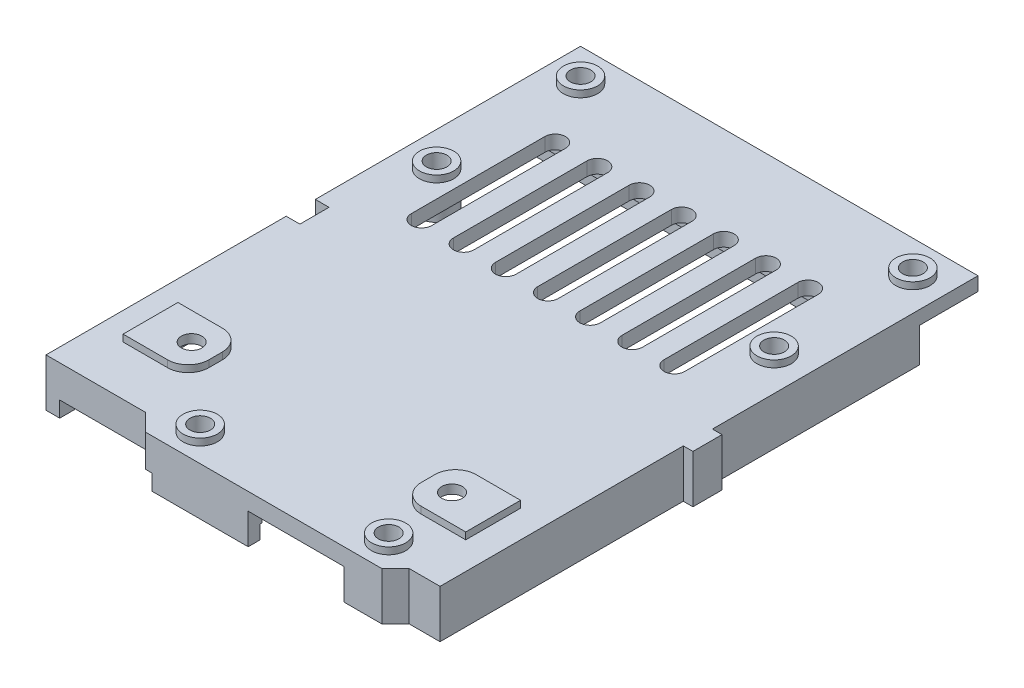
from build123d import *

# Parameters (mm, degrees)
SKETCH1_W            = 58
SKETCH1_H            = 81
SKETCH1_R            = 1.5
BOSS_EXTRUDE1_DEPTH  = 2
SKETCH2_W            = 14
SKETCH2_H            = 2
SKETCH2_W_2          = 2
SKETCH2_H_2          = 65.5
SKETCH2_H_3          = 66
SKETCH2_W_3          = 2.5
SKETCH2_W_4          = 15
BOSS_EXTRUDE2_DEPTH  = 0.5
SKETCH5_W            = 14
SKETCH5_H            = 2
BOSS_EXTRUDE3_DEPTH  = 4.5
BOSS_EXTRUDE4_DEPTH  = 2.7
SKETCH7_R            = 1.5
CUT_EXTRUDE1_DEPTH   = 1.7
SKETCH8_R            = 1.5
BOSS_EXTRUDE5_DEPTH  = 1
SKETCH9_R            = 2.5
SKETCH9_R_2          = 1.5
BOSS_EXTRUDE6_DEPTH  = 1
BOSS_EXTRUDE7_START  = 3
BOSS_EXTRUDE7_DEPTH  = 3
SKETCH11_W           = 2
SKETCH11_H           = 4.25
CUT_EXTRUDE2_DEPTH   = 51.450470761
SKETCH12_W           = 1.7
SKETCH12_H           = 6
BOSS_EXTRUDE8_DEPTH  = 3
SKETCH13_W           = 1.4
SKETCH13_H           = 4.25
BOSS_EXTRUDE9_DEPTH  = 7
SKETCH14_W           = 2.5
SKETCH14_H           = 2.5
BOSS_EXTRUDE10_DEPTH = 2.7
CUT_EXTRUDE3_DEPTH   = 51.886245686
SKETCH17_W           = 27.5
SKETCH17_H           = 0.29
SKETCH17_W_2         = 5.5
SKETCH17_W_3         = 37.5
SKETCH17_W_4         = 16.5
SKETCH17_W_5         = 0.5
CUT_EXTRUDE4_DEPTH   = 2


with BuildPart() as part:
    # Sketch1 → Boss-Extrude1 (new body)
    with BuildSketch(Plane(origin=(0, 0, 0), x_dir=(1, 0, 0), z_dir=(0, 1, 0))):
        Rectangle(SKETCH1_W, SKETCH1_H)
        with Locations(Location((24.25, 35.75, 0), (0, 0, 270))):
            Circle(SKETCH1_R, mode=Mode.SUBTRACT)
        with Locations(Location((-24.25, 35.75, 0), (0, 0, 90))):
            Circle(SKETCH1_R, mode=Mode.SUBTRACT)
        with Locations(Location((24, 15.75, 0), (0, 0, 270))):
            Circle(SKETCH1_R, mode=Mode.SUBTRACT)
        with Locations(Location((-24, 14.5, 0), (0, 0, 90))):
            Circle(SKETCH1_R, mode=Mode.SUBTRACT)
        with Locations(Location((19, -26.25, 0), (0, 0, 270))):
            Circle(SKETCH1_R, mode=Mode.SUBTRACT)
        with Locations(Location((19.5, -36, 0), (0, 0, 270))):
            Circle(SKETCH1_R, mode=Mode.SUBTRACT)
        with Locations(Location((-8, -36, 0), (0, 0, 270))):
            Circle(SKETCH1_R, mode=Mode.SUBTRACT)
        with Locations(Location((-19, -26.25, 0), (0, 0, 90))):
            Circle(SKETCH1_R, mode=Mode.SUBTRACT)
        with BuildLine():
            Line((19.7, 26.5), (19.7, 7))
            ThreePointArc((19.7, 7), (18.2, 5.5), (16.7, 7))
            Line((16.7, 7), (16.7, 26.5))
            ThreePointArc((16.7, 26.5), (18.2, 28), (19.7, 26.5))
        make_face(mode=Mode.SUBTRACT)
        with BuildLine():
            Line((13.55, 26.5), (13.55, 7))
            ThreePointArc((13.55, 7), (12.05, 5.5), (10.55, 7))
            Line((10.55, 7), (10.55, 26.5))
            ThreePointArc((10.55, 26.5), (12.05, 28), (13.55, 26.5))
        make_face(mode=Mode.SUBTRACT)
        with BuildLine():
            Line((7.4, 26.5), (7.4, 7))
            ThreePointArc((7.4, 7), (5.9, 5.5), (4.4, 7))
            Line((4.4, 7), (4.4, 26.5))
            ThreePointArc((4.4, 26.5), (5.9, 28), (7.4, 26.5))
        make_face(mode=Mode.SUBTRACT)
        with BuildLine():
            Line((1.25, 26.5), (1.25, 7))
            ThreePointArc((1.25, 7), (-0.25, 5.5), (-1.75, 7))
            Line((-1.75, 7), (-1.75, 26.5))
            ThreePointArc((-1.75, 26.5), (-0.25, 28), (1.25, 26.5))
        make_face(mode=Mode.SUBTRACT)
        with BuildLine():
            Line((-4.9, 26.5), (-4.9, 7))
            ThreePointArc((-4.9, 7), (-6.4, 5.5), (-7.9, 7))
            Line((-7.9, 7), (-7.9, 26.5))
            ThreePointArc((-7.9, 26.5), (-6.4, 28), (-4.9, 26.5))
        make_face(mode=Mode.SUBTRACT)
        with BuildLine():
            Line((-11.05, 26.5), (-11.05, 7))
            ThreePointArc((-11.05, 7), (-12.55, 5.5), (-14.05, 7))
            Line((-14.05, 7), (-14.05, 26.5))
            ThreePointArc((-14.05, 26.5), (-12.55, 28), (-11.05, 26.5))
        make_face(mode=Mode.SUBTRACT)
        with BuildLine():
            Line((-17.2, 26.5), (-17.2, 7))
            ThreePointArc((-17.2, 7), (-18.7, 5.5), (-20.2, 7))
            Line((-20.2, 7), (-20.2, 26.5))
            ThreePointArc((-20.2, 26.5), (-18.7, 28), (-17.2, 26.5))
        make_face(mode=Mode.SUBTRACT)
    extrude(amount=BOSS_EXTRUDE1_DEPTH)

    # Sketch2 → Boss-Extrude2 (add)
    with BuildSketch(Plane.XZ):
        with Locations((10, 39)):
            Rectangle(SKETCH2_W, SKETCH2_H)
        with Locations((-28, 2.75)):
            Rectangle(SKETCH2_W_2, SKETCH2_H_2)
        Polygon((29, -30), (27, -30), (-27, -30), (-27, -32), (29, -32), align=None)
        with Locations((-28, -31)):
            Rectangle(SKETCH2_W_2, SKETCH2_H)
        with Locations((28, 3)):
            Rectangle(SKETCH2_W_2, SKETCH2_H_3)
        with Locations((25.75, 37)):
            Rectangle(SKETCH2_W_3, SKETCH2_H)
        with Locations((28, 37)):
            Rectangle(SKETCH2_W_2, SKETCH2_H)
        Polygon((22.5, 40), (24.5, 38), (24.5, 36), (22.5, 38), (17, 38), (17, 40), align=None)
        with Locations((-4.5, 39)):
            Rectangle(SKETCH2_W_4, SKETCH2_H)
        Polygon((-14.5, 37.5), (-12, 37.5), (-12, 38), (-12, 40), align=None)
        Polygon((-27, 37.5), (-27, 35.5), (-12, 35.5), (-12, 37.5), (-14.5, 37.5), align=None)
        with Locations((-28, 36.5)):
            Rectangle(SKETCH2_W_2, SKETCH2_H)
    extrude(amount=BOSS_EXTRUDE2_DEPTH)

    # Sketch5 → Boss-Extrude3 (add)
    with BuildSketch(Plane.XZ.offset(0.5)):
        Polygon((27, -30), (-27, -30), (-27, 37.5), (-29, 37.5), (-29, -32), (29, -32), (29, 38), (24.5, 38), (22.5, 40), (17, 40), (17, 38), (22.5, 38), (24.5, 36), (27, 36), align=None)
        with Locations((-4, 39)):
            Rectangle(SKETCH5_W, SKETCH5_H)
    extrude(amount=BOSS_EXTRUDE3_DEPTH)

    # Sketch6 → Boss-Extrude4 (add)
    with BuildSketch(Plane.XZ):
        Polygon((-11, 38), (-11, 40), (-12, 40), (-14.5, 37.5), (-27, 37.5), (-27, 35.5), (-12, 35.5), (-12, 38), align=None)
    extrude(amount=BOSS_EXTRUDE4_DEPTH)

    # Sketch7 → Cut-Extrude1 (cut)
    # profile 1 of 2: a face of its own
    with BuildSketch(Plane.XZ):
        with BuildLine():
            Line((-18.5, 30.25), (-25, 30.25))
            Line((-25, 30.25), (-25, 22.25))
            Line((-25, 22.25), (-18.5, 22.25))
            ThreePointArc((-18.5, 22.25), (-16.378679656, 23.128679656), (-15.5, 25.25))
            Line((-15.5, 25.25), (-15.5, 27.25))
            ThreePointArc((-15.5, 27.25), (-16.378679656, 29.371320344), (-18.5, 30.25))
        make_face()
        with Locations(Location((-19, 26.25, 0), (0, 0, 270))):
            Circle(SKETCH7_R, mode=Mode.SUBTRACT)
    # profile 2 of 2: a face of its own
    with BuildSketch(Plane.XZ):
        with BuildLine():
            ThreePointArc((18.5, 30.25), (16.378679656, 29.371320344), (15.5, 27.25))
            Line((15.5, 27.25), (15.5, 25.25))
            ThreePointArc((15.5, 25.25), (16.378679656, 23.128679656), (18.5, 22.25))
            Line((18.5, 22.25), (25, 22.25))
            Line((25, 22.25), (25, 30.25))
            Line((25, 30.25), (18.5, 30.25))
        make_face()
        with Locations(Location((19, 26.25, 0), (0, 0, 270))):
            Circle(SKETCH7_R, mode=Mode.SUBTRACT)
    extrude(amount=-CUT_EXTRUDE1_DEPTH, mode=Mode.SUBTRACT)

    # Sketch8 → Boss-Extrude5 (add)
    # profile 1 of 2: a face of its own
    with BuildSketch(Plane(origin=(0, 2, 0), x_dir=(1, 0, 0), z_dir=(0, 1, 0))):
        with BuildLine():
            Line((25, -22.25), (18.5, -22.25))
            ThreePointArc((18.5, -22.25), (16.378679656, -23.128679656), (15.5, -25.25))
            Line((15.5, -25.25), (15.5, -27.25))
            ThreePointArc((15.5, -27.25), (16.378679656, -29.371320344), (18.5, -30.25))
            Line((18.5, -30.25), (25, -30.25))
            Line((25, -30.25), (25, -22.25))
        make_face()
        with Locations(Location((19, -26.25, 0), (0, 0, 90))):
            Circle(SKETCH8_R, mode=Mode.SUBTRACT)
    # profile 2 of 2: a face of its own
    with BuildSketch(Plane(origin=(0, 2, 0), x_dir=(1, 0, 0), z_dir=(0, 1, 0))):
        with BuildLine():
            Line((-18.5, -22.25), (-25, -22.25))
            Line((-25, -22.25), (-25, -30.25))
            Line((-25, -30.25), (-18.5, -30.25))
            ThreePointArc((-18.5, -30.25), (-16.378679656, -29.371320344), (-15.5, -27.25))
            Line((-15.5, -27.25), (-15.5, -25.25))
            ThreePointArc((-15.5, -25.25), (-16.378679656, -23.128679656), (-18.5, -22.25))
        make_face()
        with Locations(Location((-19, -26.25, 0), (0, 0, 90))):
            Circle(SKETCH8_R, mode=Mode.SUBTRACT)
    extrude(amount=BOSS_EXTRUDE5_DEPTH)

    # Sketch9 → Boss-Extrude6 (add)
    # profile 1 of 6: a face of its own
    with BuildSketch(Plane(origin=(0, 2, 0), x_dir=(1, 0, 0), z_dir=(0, 1, 0))):
        with Locations(Location((-24.25, 35.75, 0), (0, 0, 270))):
            Circle(SKETCH9_R)
        with Locations(Location((-24.25, 35.75, 0), (0, 0, 90))):
            Circle(SKETCH9_R_2, mode=Mode.SUBTRACT)
    # profile 2 of 6: a face of its own
    with BuildSketch(Plane(origin=(0, 2, 0), x_dir=(1, 0, 0), z_dir=(0, 1, 0))):
        with Locations(Location((-24, 14.5, 0), (0, 0, 270))):
            Circle(SKETCH9_R)
        with Locations(Location((-24, 14.5, 0), (0, 0, 90))):
            Circle(SKETCH9_R_2, mode=Mode.SUBTRACT)
    # profile 3 of 6: a face of its own
    with BuildSketch(Plane(origin=(0, 2, 0), x_dir=(1, 0, 0), z_dir=(0, 1, 0))):
        with Locations(Location((-8, -36, 0), (0, 0, 270))):
            Circle(SKETCH9_R)
        with Locations(Location((-8, -36, 0), (0, 0, 270))):
            Circle(SKETCH9_R_2, mode=Mode.SUBTRACT)
    # profile 4 of 6: a face of its own
    with BuildSketch(Plane(origin=(0, 2, 0), x_dir=(1, 0, 0), z_dir=(0, 1, 0))):
        with Locations(Location((19.5, -36, 0), (0, 0, 270))):
            Circle(SKETCH9_R)
        with Locations(Location((19.5, -36, 0), (0, 0, 270))):
            Circle(SKETCH9_R_2, mode=Mode.SUBTRACT)
    # profile 5 of 6: a face of its own
    with BuildSketch(Plane(origin=(0, 2, 0), x_dir=(1, 0, 0), z_dir=(0, 1, 0))):
        with Locations(Location((24, 15.75, 0), (0, 0, 90))):
            Circle(SKETCH9_R)
        with Locations(Location((24, 15.75, 0), (0, 0, 90))):
            Circle(SKETCH9_R_2, mode=Mode.SUBTRACT)
    # profile 6 of 6: a face of its own
    with BuildSketch(Plane(origin=(0, 2, 0), x_dir=(1, 0, 0), z_dir=(0, 1, 0))):
        with Locations(Location((24.25, 35.75, 0), (0, 0, 90))):
            Circle(SKETCH9_R)
        with Locations(Location((24.25, 35.75, 0), (0, 0, 90))):
            Circle(SKETCH9_R_2, mode=Mode.SUBTRACT)
    extrude(amount=BOSS_EXTRUDE6_DEPTH)

    # Sketch10 → Boss-Extrude7 (add)
    with BuildSketch(Plane.XZ.offset(BOSS_EXTRUDE7_START)):
        with BuildLine():
            Line((-5.5, 36), (-6.5, 36))
            ThreePointArc((-6.5, 36), (-8, 34.5), (-9.5, 36))
            Line((-9.5, 36), (-10.5, 36))
            ThreePointArc((-10.5, 36), (-8, 33.5), (-5.5, 36))
        make_face()
        with BuildLine():
            ThreePointArc((-9.5, 36), (-8, 37.5), (-6.5, 36))
            Line((-6.5, 36), (-5.5, 36))
            ThreePointArc((-5.5, 36), (-5.763932023, 37.118033989), (-6.5, 38))
            Line((-6.5, 38), (-9.5, 38))
            ThreePointArc((-9.5, 38), (-10.236067977, 37.118033989), (-10.5, 36))
            Line((-10.5, 36), (-9.5, 36))
        make_face()
        with BuildLine():
            ThreePointArc((-6.5, 38), (-5.763932023, 37.118033989), (-5.5, 36))
            Line((-5.5, 36), (-5.5, 38))
            Line((-5.5, 38), (-6.5, 38))
        make_face()
        with BuildLine():
            Line((-10.5, 38), (-10.5, 36))
            ThreePointArc((-10.5, 36), (-10.236067977, 37.118033989), (-9.5, 38))
            Line((-9.5, 38), (-10.5, 38))
        make_face()
        with BuildLine():
            ThreePointArc((21, 38), (21.736067977, 37.118033989), (22, 36))
            Line((22, 36), (22, 38))
            Line((22, 38), (21, 38))
        make_face()
        with BuildLine():
            ThreePointArc((18, 36), (19.5, 37.5), (21, 36))
            Line((21, 36), (22, 36))
            ThreePointArc((22, 36), (21.736067977, 37.118033989), (21, 38))
            Line((21, 38), (18, 38))
            ThreePointArc((18, 38), (17.263932023, 37.118033989), (17, 36))
            Line((17, 36), (18, 36))
        make_face()
        with BuildLine():
            Line((22, 36), (21, 36))
            ThreePointArc((21, 36), (19.5, 34.5), (18, 36))
            Line((18, 36), (17, 36))
            ThreePointArc((17, 36), (19.5, 33.5), (22, 36))
        make_face()
        with BuildLine():
            Line((17, 38), (17, 36))
            ThreePointArc((17, 36), (17.263932023, 37.118033989), (18, 38))
            Line((18, 38), (17, 38))
        make_face()
        with BuildLine():
            Line((27, -18.25), (27, -13.25))
            Line((27, -13.25), (24, -13.25))
            ThreePointArc((24, -13.25), (25.767766953, -13.982233047), (26.5, -15.75))
            ThreePointArc((26.5, -15.75), (25.767766953, -17.517766953), (24, -18.25))
            Line((24, -18.25), (27, -18.25))
        make_face()
        with BuildLine():
            ThreePointArc((26.5, -15.75), (25.767766953, -13.982233047), (24, -13.25))
            Line((24, -13.25), (24, -14.25))
            ThreePointArc((24, -14.25), (25.060660172, -14.689339828), (25.5, -15.75))
            ThreePointArc((25.5, -15.75), (25.060660172, -16.810660172), (24, -17.25))
            Line((24, -17.25), (24, -18.25))
            ThreePointArc((24, -18.25), (25.767766953, -17.517766953), (26.5, -15.75))
        make_face()
        with BuildLine():
            Line((24, -14.25), (24, -13.25))
            ThreePointArc((24, -13.25), (21.5, -15.75), (24, -18.25))
            Line((24, -18.25), (24, -17.25))
            ThreePointArc((24, -17.25), (22.5, -15.75), (24, -14.25))
        make_face()
        with BuildLine():
            ThreePointArc((26.5, -15.75), (25.767766953, -13.982233047), (24, -13.25))
            Line((24, -13.25), (24, -14.25))
            ThreePointArc((24, -14.25), (25.060660172, -14.689339828), (25.5, -15.75))
            ThreePointArc((25.5, -15.75), (25.060660172, -16.810660172), (24, -17.25))
            Line((24, -17.25), (24, -18.25))
            ThreePointArc((24, -18.25), (25.767766953, -17.517766953), (26.5, -15.75))
        make_face()
        with BuildLine():
            Line((24, -14.25), (24, -13.25))
            ThreePointArc((24, -13.25), (21.5, -15.75), (24, -18.25))
            Line((24, -18.25), (24, -17.25))
            ThreePointArc((24, -17.25), (22.5, -15.75), (24, -14.25))
        make_face()
        with BuildLine():
            ThreePointArc((-24, -17), (-26.5, -14.5), (-24, -12))
            Line((-24, -12), (-27, -12))
            Line((-27, -12), (-27, -17))
            Line((-27, -17), (-24, -17))
        make_face()
        with BuildLine():
            ThreePointArc((-21.5, -14.5), (-22.232233047, -12.732233047), (-24, -12))
            Line((-24, -12), (-24, -13))
            ThreePointArc((-24, -13), (-22.939339828, -13.439339828), (-22.5, -14.5))
            ThreePointArc((-22.5, -14.5), (-22.939339828, -15.560660172), (-24, -16))
            Line((-24, -16), (-24, -17))
            ThreePointArc((-24, -17), (-22.232233047, -16.267766953), (-21.5, -14.5))
        make_face()
        with BuildLine():
            Line((-24, -13), (-24, -12))
            ThreePointArc((-24, -12), (-26.5, -14.5), (-24, -17))
            Line((-24, -17), (-24, -16))
            ThreePointArc((-24, -16), (-25.5, -14.5), (-24, -13))
        make_face()
        with BuildLine():
            ThreePointArc((-21.5, -14.5), (-22.232233047, -12.732233047), (-24, -12))
            Line((-24, -12), (-24, -13))
            ThreePointArc((-24, -13), (-22.939339828, -13.439339828), (-22.5, -14.5))
            ThreePointArc((-22.5, -14.5), (-22.939339828, -15.560660172), (-24, -16))
            Line((-24, -16), (-24, -17))
            ThreePointArc((-24, -17), (-22.232233047, -16.267766953), (-21.5, -14.5))
        make_face()
        with BuildLine():
            Line((-24, -13), (-24, -12))
            ThreePointArc((-24, -12), (-26.5, -14.5), (-24, -17))
            Line((-24, -17), (-24, -16))
            ThreePointArc((-24, -16), (-25.5, -14.5), (-24, -13))
        make_face()
    extrude(amount=-BOSS_EXTRUDE7_DEPTH)

    # Sketch11 → Cut-Extrude2 (cut, through all)
    with BuildSketch(Plane.XZ.offset(5)):
        with Locations((-28, 0.325)):
            Rectangle(SKETCH11_W, SKETCH11_H)
    extrude(amount=-CUT_EXTRUDE2_DEPTH, mode=Mode.SUBTRACT)

    # Sketch12 → Boss-Extrude8 (add)
    with BuildSketch(Plane.XZ):
        with Locations((-26.15, 0.325)):
            Rectangle(SKETCH12_W, SKETCH12_H)
    extrude(amount=BOSS_EXTRUDE8_DEPTH)

    # Sketch13 → Boss-Extrude9 (add)
    with BuildSketch(Plane.XZ.offset(5)):
        with Locations((29.7, 0.375)):
            Rectangle(SKETCH13_W, SKETCH13_H)
    extrude(amount=-BOSS_EXTRUDE9_DEPTH)

    # Sketch14 → Boss-Extrude10 (add)
    with BuildSketch(Plane.XZ.offset(2.7)):
        with Locations((-10.75, 36.75)):
            Rectangle(SKETCH14_W, SKETCH14_H)
    extrude(amount=-BOSS_EXTRUDE10_DEPTH)

    # Sketch15 → Cut-Extrude3 (cut, through all)
    with BuildSketch(Plane.XZ):
        Polygon((-29, 40.5), (-29, 37.5), (-14.5, 37.5), (-12, 40), (22.5, 40), (24.5, 38), (29, 38), (29, 40.5), align=None)
    extrude(amount=-CUT_EXTRUDE3_DEPTH, mode=Mode.SUBTRACT)

    # Sketch17 → Cut-Extrude4 (cut)
    with BuildSketch(Plane.XZ.offset(5)):
        with Locations((3.25, 38.145)):
            Rectangle(SKETCH17_W, SKETCH17_H)
        with Locations((19.75, 38.145)):
            Rectangle(SKETCH17_W_2, SKETCH17_H)
        with Locations((8.25, -30.145)):
            Rectangle(SKETCH17_W_3, SKETCH17_H)
        with Locations((-18.75, -30.145)):
            Rectangle(SKETCH17_W_4, SKETCH17_H)
        with Locations((-10.75, 38.145)):
            Rectangle(SKETCH17_W_5, SKETCH17_H)
    extrude(amount=-CUT_EXTRUDE4_DEPTH, mode=Mode.SUBTRACT)


solid = part.part
